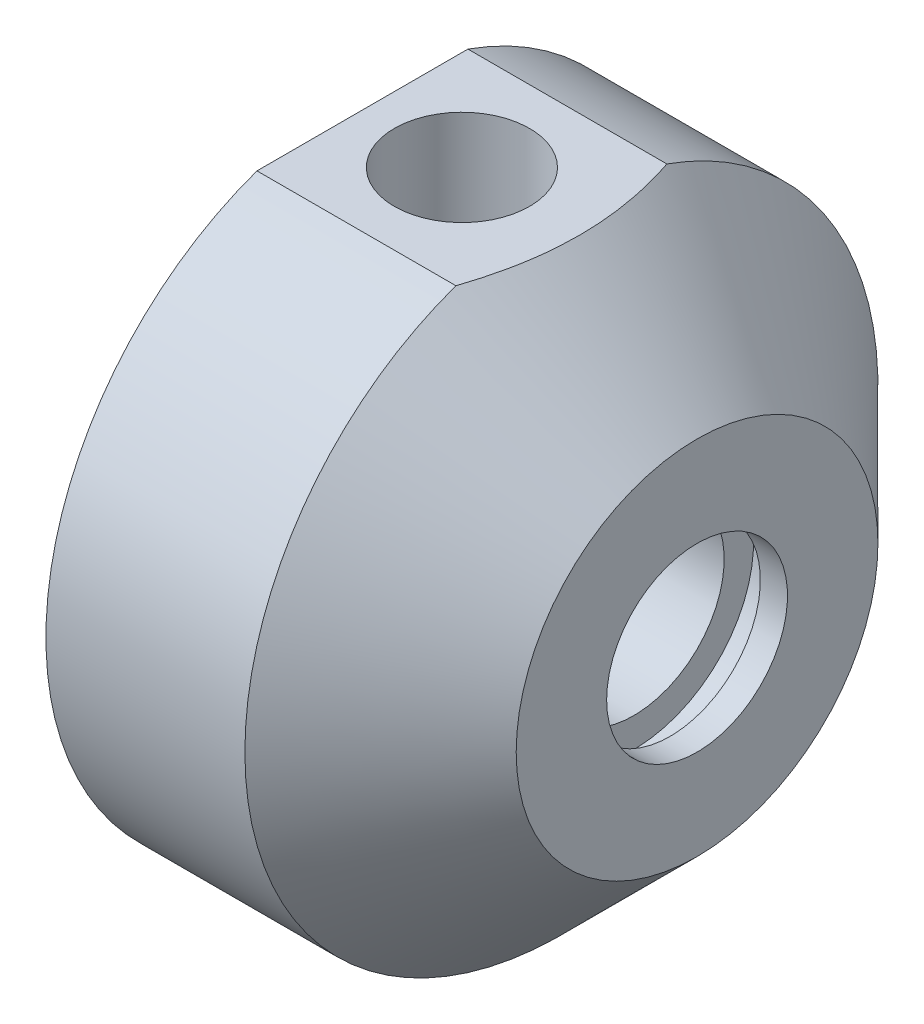
from build123d import *

# Parameters (mm, degrees)
ESQUISSE2_W                  = 51
ESQUISSE2_H                  = 6
ENL_V_MAT_EXTRU_1_DEPTH      = 25
ENL_V_MAT_EXTRU_2_REACH      = 70
ESQUISSE3_R                  = 7.475
ESQUISSE4_R                  = 3
ENL_V_MAT_EXTRU_3_DEPTH      = 20
R_P_TITION_CIRCULAIRE1_COUNT = 4
ESQUISSE7_R                  = 3
ENL_V_MAT_EXTRU_5_DEPTH      = 11
ENL_V_MAT_EXTRU_6_REACH      = 61
ESQUISSE8_R                  = 1


with BuildPart() as part:
    # Esquisse1 → Base-Révolution (revolve)
    with BuildSketch(Plane.XY):
        Polygon((-26, 16), (-26, 20), (-23, 20), (-23, 18.5), (-20.4, 18.5), (-20.4, 20), (-16, 20), (-16, 35), (6, 35), (21, 20), (21, 10), (18, 10), (18, 13.25), (14, 13.25), (14, 10), (3.732050808, 10), (2, 13), (-23, 13), align=None)
    revolve(axis=Axis((-21, 0, 0), (1, 0, 0)))

    # Esquisse2 → Enlèv. mat.-Extru.1 (cut, symmetric)
    with BuildSketch(Plane.XY):
        with Locations((-5.5, 36)):
            Rectangle(ESQUISSE2_W, ESQUISSE2_H)
    extrude(amount=ENL_V_MAT_EXTRU_1_DEPTH, both=True, mode=Mode.SUBTRACT)

    # Esquisse3 → Enlèv. mat.-Extru.2 (cut, up to next)
    with BuildSketch(Plane(origin=(0, 33, 0), x_dir=(-1, 0, 0), z_dir=(0, 1, 0)), mode=Mode.PRIVATE) as enl_v_mat_extru_2_sk1:
        with Locations((5, 0)):
            Circle(ESQUISSE3_R)
    enl_v_mat_extru_2_tool1 = extrude(enl_v_mat_extru_2_sk1.sketch, amount=-ENL_V_MAT_EXTRU_2_REACH, mode=Mode.PRIVATE) & part.part
    add(enl_v_mat_extru_2_tool1.solids().sort_by_distance((-5, 33, 0))[0], mode=Mode.SUBTRACT)

    # Esquisse4 → Enlèv. mat.-Extru.3 (cut)
    with BuildSketch(Plane.ZY.offset(16)):
        with Locations((19.798989873, -19.798989873)):
            Circle(ESQUISSE4_R)
    enl_v_mat_extru_3 = extrude(amount=-ENL_V_MAT_EXTRU_3_DEPTH, mode=Mode.SUBTRACT)

    # Répétition circulaire1: Enlèv. mat.-Extru.3 ×4 about axis
    r_p_tition_circulaire1_axis = Axis((-21, 0, 0), (1, 0, 0))
    for i in range(1, R_P_TITION_CIRCULAIRE1_COUNT):
        add(enl_v_mat_extru_3.rotate(r_p_tition_circulaire1_axis, i * 360 / R_P_TITION_CIRCULAIRE1_COUNT), mode=Mode.SUBTRACT)

    # Esquisse7 → Enlèv. mat.-Extru.5 (cut)
    with BuildSketch(Plane.XY.offset(-35)):
        with Locations((-5, 0.349567503)):
            Circle(ESQUISSE7_R)
    extrude(amount=ENL_V_MAT_EXTRU_5_DEPTH, mode=Mode.SUBTRACT)

    # Esquisse8 → Enlèv. mat.-Extru.6 (cut, up to next)
    with BuildSketch(Plane(origin=(0, 0, -24), x_dir=(-1, 0, 0), z_dir=(0, 0, -1)), mode=Mode.PRIVATE) as enl_v_mat_extru_6_sk1:
        with Locations((5, 0.349567503)):
            Circle(ESQUISSE8_R)
    enl_v_mat_extru_6_tool1 = extrude(enl_v_mat_extru_6_sk1.sketch, amount=-ENL_V_MAT_EXTRU_6_REACH, mode=Mode.PRIVATE) & part.part
    add(enl_v_mat_extru_6_tool1.solids().sort_by_distance((-5, 0.349568, -24))[0], mode=Mode.SUBTRACT)


solid = part.part
